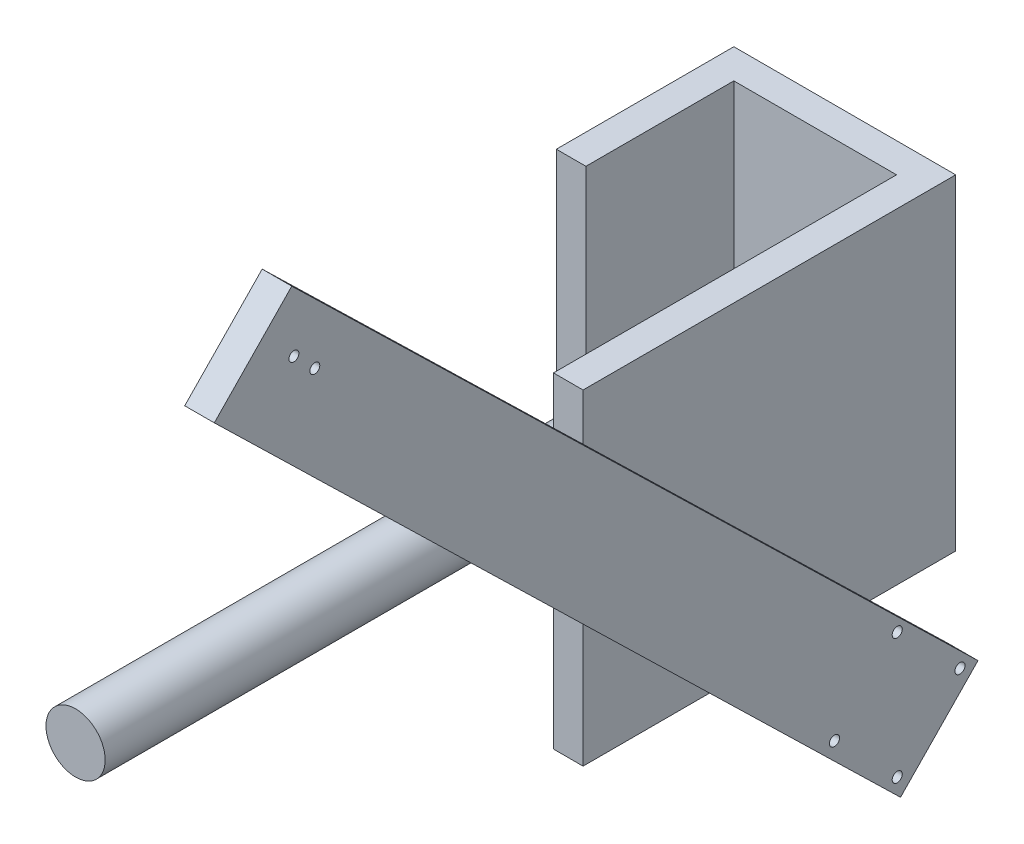
from build123d import *

# Parameters (mm, degrees)
SKETCH1_R           = 3.35
SKETCH1_R_2         = 3.4
BOSS_EXTRUDE1_DEPTH = 20
SKETCH2_W           = 231.929502284
SKETCH2_H           = 220.245456765
BOSS_EXTRUDE2_DEPTH = 20
SKETCH3_W           = 20
SKETCH3_H           = 220.245456765
BOSS_EXTRUDE3_DEPTH = 150
SKETCH4_W           = 20
SKETCH4_H           = 220.245456765
BOSS_EXTRUDE4_DEPTH = 100
SKETCH5_R           = 20
BOSS_EXTRUDE5_DEPTH = 500


with BuildPart() as part:
    # Sketch1 → Boss-Extrude1 (new body)
    with BuildSketch(Plane.ZY.offset(22937.011755361)):
        Polygon((41237.494779256, 5557.929358856), (40773.575398624, 5106.753906388), (40825.939297891, 5052.910933366), (41289.858678523, 5504.086385835), align=None)
        with Locations((41221.902000531, 5502.053605549)):
            Circle(SKETCH1_R, mode=Mode.SUBTRACT)
        with Locations((41236.044136152, 5516.195741176)):
            Circle(SKETCH1_R, mode=Mode.SUBTRACT)
        with Locations((40870.597048417, 5108.322246569)):
            Circle(SKETCH1_R_2, mode=Mode.SUBTRACT)
        with Locations((40828.170641545, 5065.895839698)):
            Circle(SKETCH1_R_2, mode=Mode.SUBTRACT)
        with Locations((40828.170641545, 5150.74865344)):
            Circle(SKETCH1_R_2, mode=Mode.SUBTRACT)
        with Locations((40785.744234674, 5108.322246569)):
            Circle(SKETCH1_R_2, mode=Mode.SUBTRACT)
    extrude(amount=BOSS_EXTRUDE1_DEPTH)

    # Sketch2 → Boss-Extrude2 (add)
    with BuildSketch(Plane.ZY.offset(22957.011755361)):
        with Locations((40904.599781001, 5268.565849628)):
            Rectangle(SKETCH2_W, SKETCH2_H)
    extrude(amount=BOSS_EXTRUDE2_DEPTH)

    # Sketch3 → Boss-Extrude3 (add)
    with BuildSketch(Plane.ZY.offset(22957.011755361)):
        with Locations((40778.635029859, 5268.565849628)):
            Rectangle(SKETCH3_W, SKETCH3_H)
    extrude(amount=BOSS_EXTRUDE3_DEPTH)

    # Sketch4 → Boss-Extrude4 (add)
    with BuildSketch(Plane.XY.offset(40788.635029859)):
        with Locations((-23097.01175536, 5268.565849628)):
            Rectangle(SKETCH4_W, SKETCH4_H)
    extrude(amount=BOSS_EXTRUDE4_DEPTH)

    # Sketch5 → Boss-Extrude5 (add)
    with BuildSketch(Plane.XY.offset(40788.635029859)):
        with Locations((-23032.01175536, 5268.565849628)):
            Circle(SKETCH5_R)
    extrude(amount=BOSS_EXTRUDE5_DEPTH)


solid = part.part
